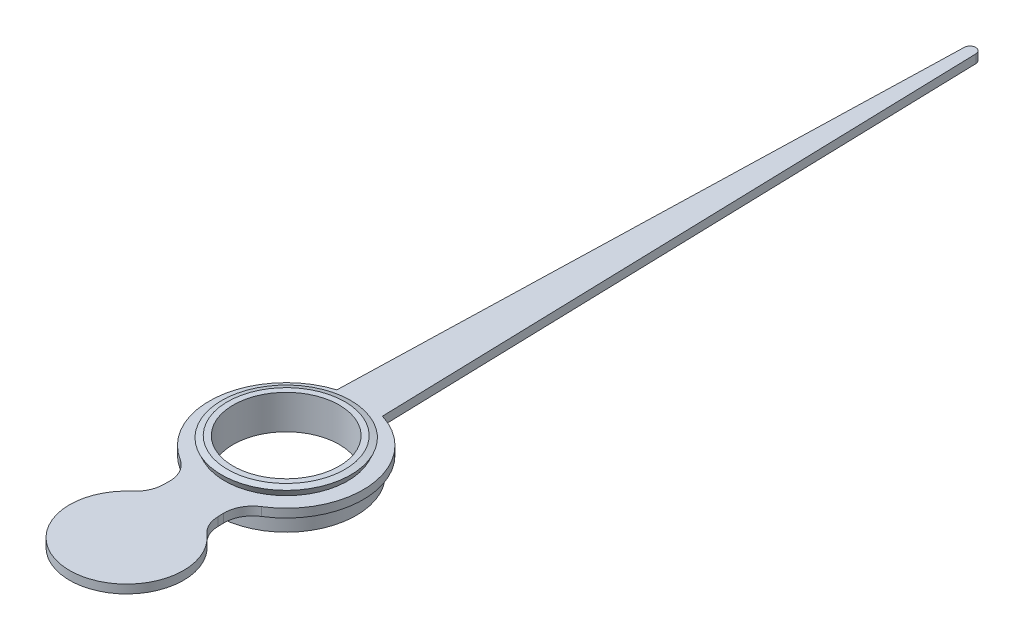
from build123d import *

# Parameters (mm, degrees)
ESQUISSE2_R        = 1.08
BOSS_EXTRU_1_DEPTH = 0.15


with BuildPart() as part:
    # Esquisse1 → Révolution1 (revolve)
    with BuildSketch(Plane.XY):
        Polygon((-1.23, 0), (-1.23, 0.3), (-1.08, 0.3), (-1.08, 0.45), (-1.13245676, 0.567603094), (-1.030107007, 0.6), (-0.93, 0.6), (-0.93, 0), align=None)
    revolve(axis=Axis((0, 0, 0), (0, 1, 0)))

    # Esquisse2 → Boss.-Extru.1 (add)
    with BuildSketch(Plane(origin=(0, 0.3, 0), x_dir=(1, 0, 0), z_dir=(0, 1, 0))):
        with BuildLine():
            Line((0.099960806, 12.002799494), (0.4, 1.289379696))
            ThreePointArc((0.4, 1.289379696), (1.338815312, 0.173417305), (0.715314881, -1.144912495))
            ThreePointArc((0.715314881, -1.144912495), (0.539593784, -1.332680285), (0.480442286, -1.582951632))
            Line((0.480442286, -1.582951632), (0.48324178, -1.682912439))
            ThreePointArc((0.48324178, -1.682912439), (0.531110798, -1.882818549), (0.655363875, -2.04657162))
            ThreePointArc((0.655363875, -2.04657162), (0, -3.801884927), (-0.655363875, -2.04657162))
            ThreePointArc((-0.655363875, -2.04657162), (-0.531110798, -1.882818549), (-0.48324178, -1.682912439))
            Line((-0.48324178, -1.682912439), (-0.480442286, -1.582951632))
            ThreePointArc((-0.480442286, -1.582951632), (-0.539593784, -1.332680285), (-0.715314881, -1.144912495))
            ThreePointArc((-0.715314881, -1.144912495), (-1.338815312, 0.173417305), (-0.4, 1.289379696))
            Line((-0.4, 1.289379696), (-0.099960806, 12.002799494))
            ThreePointArc((-0.099960806, 12.002799494), (0, 12.1), (0.099960806, 12.002799494))
        make_face()
        Circle(ESQUISSE2_R, mode=Mode.SUBTRACT)
    extrude(amount=BOSS_EXTRU_1_DEPTH)


solid = part.part
